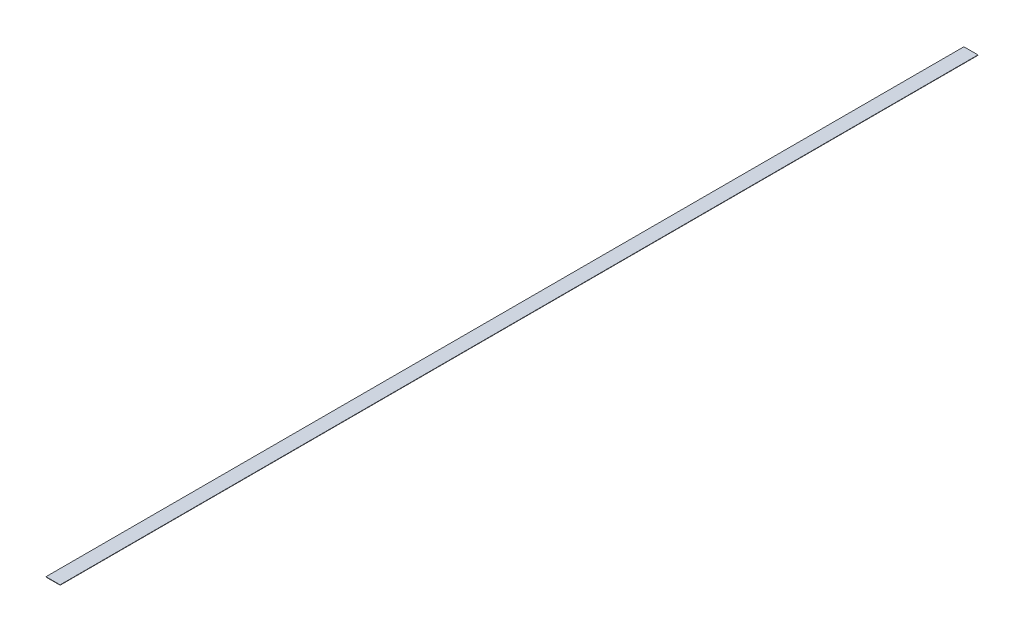
from build123d import *

# Parameters (mm, degrees)
SKETCH1_W           = 50.8
SKETCH1_H           = 3302
BOSS_EXTRUDE1_DEPTH = 1.27


with BuildPart() as part:
    # Sketch1 → Boss-Extrude1 (new body)
    with BuildSketch(Plane(origin=(0, 0, 0), x_dir=(1, 0, 0), z_dir=(0, 1, 0))):
        Rectangle(SKETCH1_W, SKETCH1_H)
    extrude(amount=BOSS_EXTRUDE1_DEPTH)


solid = part.part
